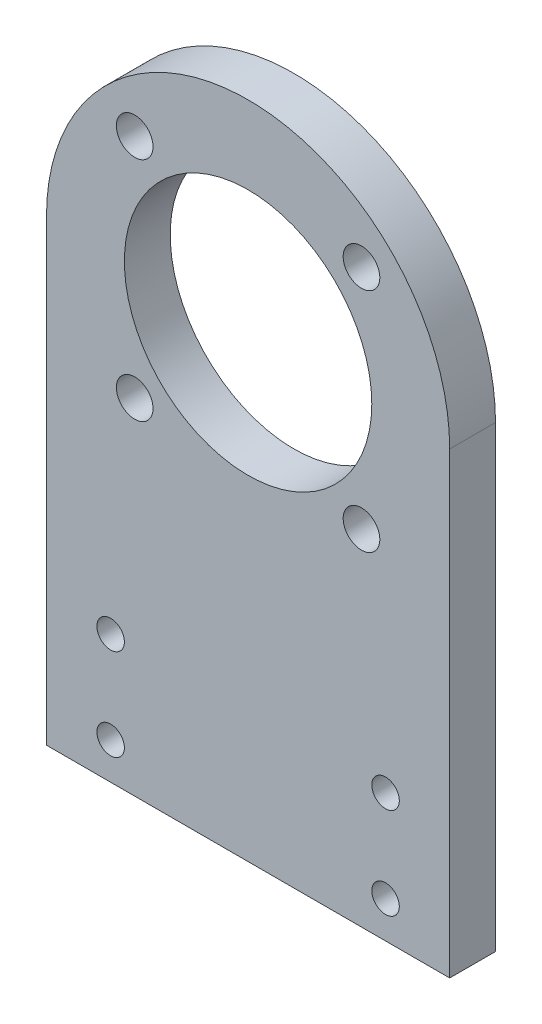
from build123d import *

# Parameters (mm, degrees)
SKETCH_1_R          = 1.5
SKETCH_1_R_2        = 13.5
EXTRUDE_1_DEPTH     = 5
SKETCH_2_R          = 2
CUT_EXTRUDE_1_DEPTH = 6


with BuildPart() as part:
    # 草图1 → 凸台-拉伸1 (new body)
    with BuildSketch(Plane.XY):
        with BuildLine():
            Line((-22, 0), (22, 0))
            Line((22, 0), (22, 50))
            ThreePointArc((22, 50), (0, 72), (-22, 50))
            Line((-22, 50), (-22, 0))
        make_face()
        with Locations((-15, 14)):
            Circle(SKETCH_1_R, mode=Mode.SUBTRACT)
        with Locations((-15, 4)):
            Circle(SKETCH_1_R, mode=Mode.SUBTRACT)
        with Locations((15, 4)):
            Circle(SKETCH_1_R, mode=Mode.SUBTRACT)
        with Locations((15, 14)):
            Circle(SKETCH_1_R, mode=Mode.SUBTRACT)
        with Locations((0, 50)):
            Circle(SKETCH_1_R_2, mode=Mode.SUBTRACT)
    extrude(amount=EXTRUDE_1_DEPTH)

    # 草图2 → 切除-拉伸1 (cut, through all)
    with BuildSketch(Plane(origin=(0, 0, 0), x_dir=(-1, 0, 0), z_dir=(0, 0, -1))):
        with Locations((12.374368671, 62.374368671)):
            Circle(SKETCH_2_R)
        with Locations((12.374368671, 37.625631329)):
            Circle(SKETCH_2_R)
        with Locations((-12.374368671, 37.625631329)):
            Circle(SKETCH_2_R)
        with Locations((-12.374368671, 62.374368671)):
            Circle(SKETCH_2_R)
    extrude(amount=-CUT_EXTRUDE_1_DEPTH, mode=Mode.SUBTRACT)


solid = part.part
